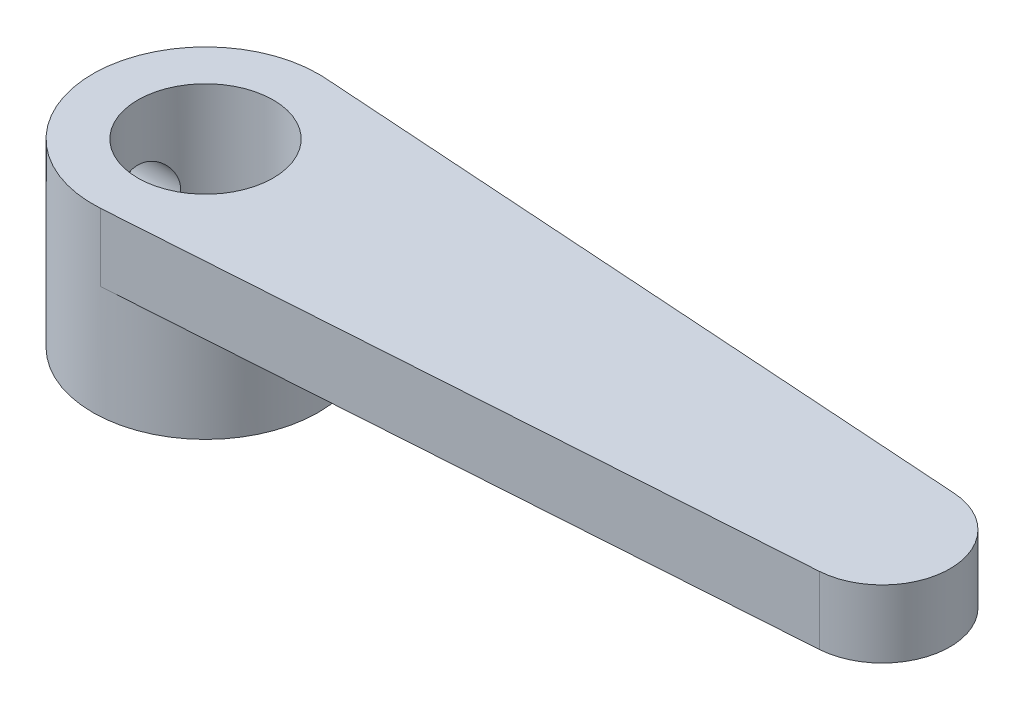
from build123d import *

# Parameters (mm, degrees)
SKETCH_1_R          = 3
EXTRUDE_1_DEPTH     = 3
SKETCH_2_R          = 5
SKETCH_2_R_2        = 3
EXTRUDE_2_DEPTH     = 5
SKETCH_3_R          = 1.5
CUT_EXTRUDE_1_DEPTH = 6


with BuildPart() as part:
    # 草圖1 → 填料-伸長1 (new body)
    with BuildSketch(Plane(origin=(0, 0, 0), x_dir=(1, 0, 0), z_dir=(0, 1, 0))):
        with BuildLine():
            Line((0.333333333, 4.988876516), (30.2, 2.993325909))
            ThreePointArc((30.2, 2.993325909), (33, 0), (30.2, -2.993325909))
            Line((30.2, -2.993325909), (0.333333333, -4.988876516))
            ThreePointArc((0.333333333, -4.988876516), (-5, 0), (0.333333333, 4.988876516))
        make_face()
        Circle(SKETCH_1_R, mode=Mode.SUBTRACT)
    extrude(amount=EXTRUDE_1_DEPTH)

    # 草圖2 → 填料-伸長2 (add)
    with BuildSketch(Plane.XZ):
        Circle(SKETCH_2_R)
        Circle(SKETCH_2_R_2, mode=Mode.SUBTRACT)
    extrude(amount=EXTRUDE_2_DEPTH)

    # 草圖3 → 除料-伸長1 (cut, through all)
    with BuildSketch(Plane(origin=(0, 0, 0), x_dir=(0, 0, -1), z_dir=(1, 0, 0))):
        with Locations((0, -1)):
            Circle(SKETCH_3_R)
    extrude(amount=-CUT_EXTRUDE_1_DEPTH, mode=Mode.SUBTRACT)


solid = part.part
